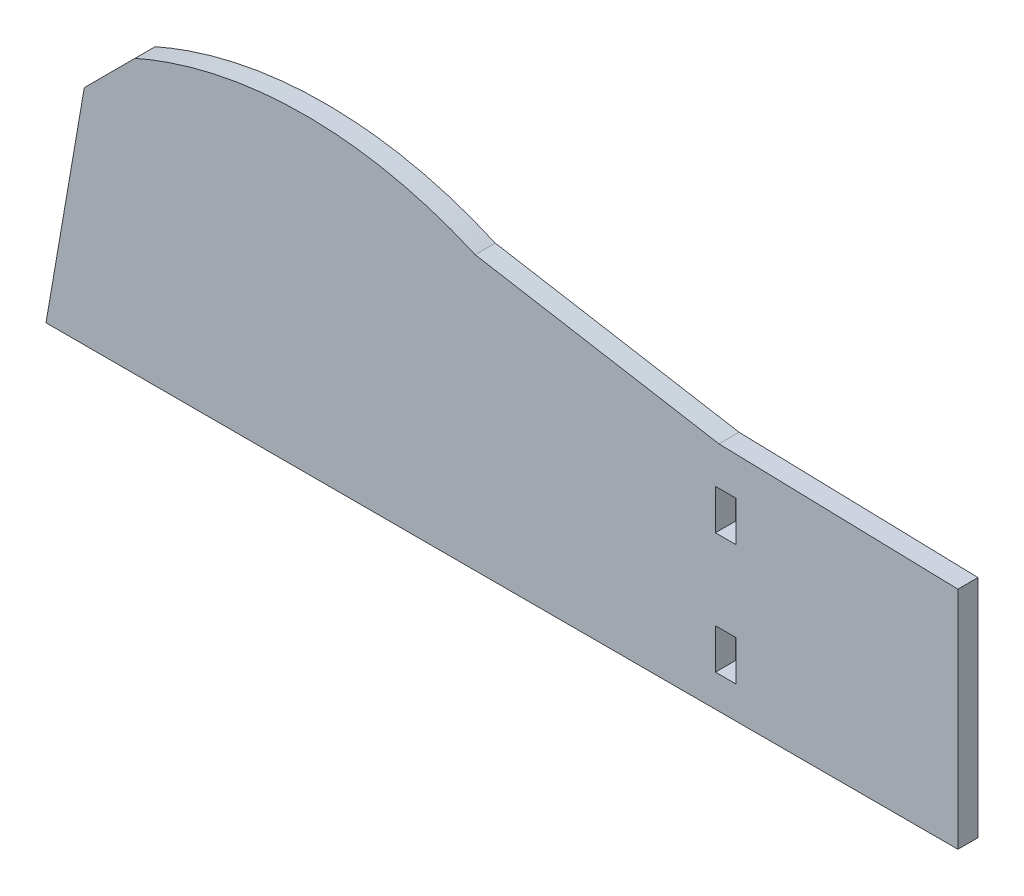
from build123d import *

# Parameters (mm, degrees)
BOSS_EXTRUDE1_DEPTH  = 3.175
SKETCH3_W            = 3.2258
SKETCH3_H            = 6.35
HOLES_FOR_TABS_DEPTH = 4.1750001


with BuildPart() as part:
    # Sketch1 → Boss-Extrude1 (new body)
    with BuildSketch(Plane.XY):
        with BuildLine():
            Line((-76.2, 43.18), (-37.713355451, 36.56692496))
            Line((-37.713355451, 36.56692496), (0, 35.56))
            Line((0, 35.56), (0, 0))
            Line((0, 0), (-143.94013079, 0))
            Line((-143.94013079, 0), (-137.895807931, 35.176631753))
            Line((-137.895807931, 35.176631753), (-129.892439684, 43.18))
            add(Edge.make_bspline(
                [(-129.892439684, 43.18), (-123.632909294, 45.955986916), (-114.625709488, 48.362317243), (-103.247996656, 48.972136691), (-95.522501134, 48.59342086), (-86.411542659, 47.027463229), (-79.726058772, 44.740816459), (-76.2, 43.18)],
                knots=[0, 0, 0, 0, 0.371232541, 0.49990694, 0.617608528, 0.790714497, 1, 1, 1, 1], degree=3))
        make_face()
    extrude(amount=BOSS_EXTRUDE1_DEPTH)

    # Sketch3 → holes for tabs (cut, through all)
    with BuildSketch(Plane.XY.offset(3.175)):
        with Locations((-36.6649, 27.305)):
            Rectangle(SKETCH3_W, SKETCH3_H)
        with Locations((-36.6649, 8.255)):
            Rectangle(SKETCH3_W, SKETCH3_H)
    extrude(amount=-HOLES_FOR_TABS_DEPTH, mode=Mode.SUBTRACT)


solid = part.part
